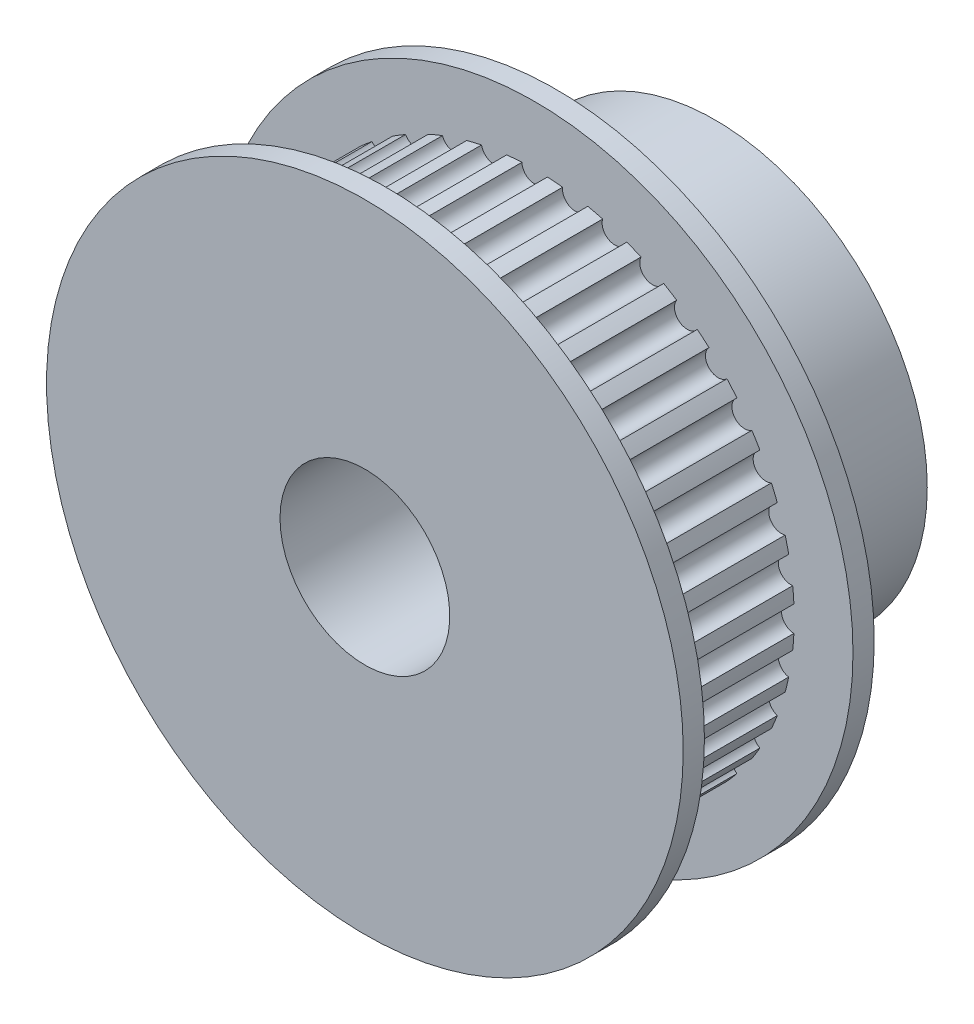
from build123d import *

# Parameters (mm, degrees)
SKETCH_1_R               = 15
EXTRUDE_1_DEPTH          = 0.5
SKETCH_2_R               = 12.23
EXTRUDE_2_DEPTH          = 7
SKETCH_8_R               = 10
EXTRUDE_4_DEPTH          = 8
CUT_EXTRUDE_3_DEPTH      = 7
SKETCH_3_R               = 15
EXTRUDE_3_DEPTH          = 1
SKETCH_6_R               = 4
CUT_EXTRUDE_2_DEPTH      = 8.5
CUT_EXTRUDE_2_DEPTH_BACK = 10
PATTERN_CIRCULAR_2_COUNT = 40


with BuildPart() as part:
    # 草圖1 → 填料-伸長1 (new body, symmetric)
    with BuildSketch(Plane.XY):
        Circle(SKETCH_1_R)
    extrude(amount=EXTRUDE_1_DEPTH, both=True)

    # 草圖2 → 填料-伸長2 (add)
    with BuildSketch(Plane.XY.offset(0.5)):
        Circle(SKETCH_2_R)
    extrude(amount=EXTRUDE_2_DEPTH)

    # 草圖8 → 填料-伸長4 (add)
    with BuildSketch(Plane(origin=(0, 0, 0), x_dir=(-1, 0, 0), z_dir=(0, 0, -1))):
        Circle(SKETCH_8_R)
    extrude(amount=EXTRUDE_4_DEPTH)

    # 草圖7 → 除料-伸長3 (cut)
    with BuildSketch(Plane.XY.offset(7.5)):
        with BuildLine():
            ThreePointArc((-0.599819459, 12.215282093), (0, 11.63), (0.599819459, 12.215282093))
            ThreePointArc((0.599819459, 12.215282093), (0, 12.23), (-0.599819459, 12.215282093))
        make_face()
    cut_extrude_3 = extrude(amount=-CUT_EXTRUDE_3_DEPTH, mode=Mode.SUBTRACT)

    # 草圖3 → 填料-伸長3 (add)
    with BuildSketch(Plane.XY.offset(7.5)):
        Circle(SKETCH_3_R)
    extrude(amount=EXTRUDE_3_DEPTH)

    # 草圖6 → 除料-伸長2 (cut, two sides)
    with BuildSketch(Plane(origin=(0, 0, -0.5), x_dir=(-1, 0, 0), z_dir=(0, 0, -1))) as cut_extrude_2_sk:
        Circle(SKETCH_6_R)
    extrude(amount=CUT_EXTRUDE_2_DEPTH, mode=Mode.SUBTRACT)
    extrude(cut_extrude_2_sk.sketch, amount=-CUT_EXTRUDE_2_DEPTH_BACK, mode=Mode.SUBTRACT)

    # 環狀複製排列2: 除料-伸長3 ×40 about axis
    pattern_circular_2_axis = Axis((0, 0, 0), (0, 0, 1))
    for i in range(1, PATTERN_CIRCULAR_2_COUNT):
        add(cut_extrude_3.rotate(pattern_circular_2_axis, i * 360 / PATTERN_CIRCULAR_2_COUNT), mode=Mode.SUBTRACT)


solid = part.part
